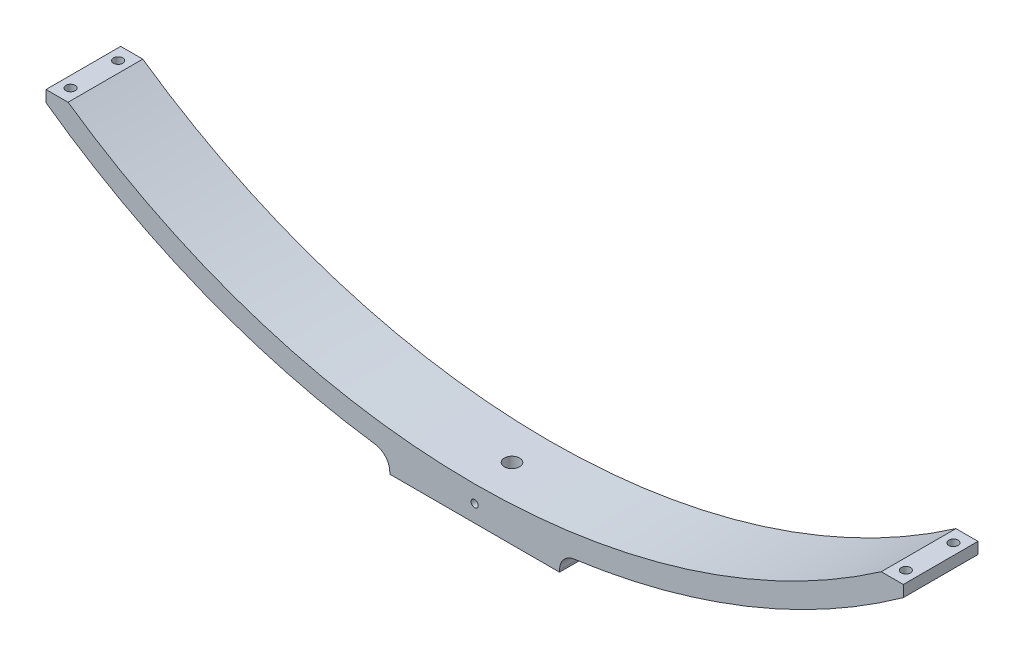
from build123d import *

# Parameters (mm, degrees)
BOSS_EXTRU_1_DEPTH       = 44
ESQUISSE2_R              = 4.5
ENL_V_MAT_EXTRU_1_DEPTH  = 96
ESQUISSE6_R              = 2.75
ENL_V_MAT_EXTRU_2_DEPTH  = 96.0000001
ESQUISSE7_R              = 4.75
ENL_V_MAT_EXTRU_3_DEPTH  = 24
ESQUISSE8_R              = 2.75
ENL_V_MAT_EXTRU_4_DEPTH  = 96.0000001
ESQUISSE9_R              = 4.75
ENL_V_MAT_EXTRU_5_DEPTH  = 24
ESQUISSE10_R             = 2.75
ENL_V_MAT_EXTRU_6_DEPTH  = 96.0000001
ESQUISSE11_R             = 4.75
ENL_V_MAT_EXTRU_8_DEPTH  = 24
ESQUISSE13_R             = 4.75
ENL_V_MAT_EXTRU_11_DEPTH = 24
TROU_TARAUD_M51_D        = 4.2
CONG_1_R                 = 10


with BuildPart() as part:
    # Esquisse1 → Boss.-Extru.1 (new body)
    with BuildSketch(Plane.XY):
        with BuildLine():
            Line((-252.5, 75), (-252.5, 68.266055554))
            ThreePointArc((-252.5, 68.266055554), (-156.243343573, 16.179149841), (-50, -10.102813546))
            Line((-50, -10.102813546), (-50, -20))
            Line((-50, -20), (50, -20))
            Line((50, -20), (50, -10.102813546))
            ThreePointArc((50, -10.102813546), (156.243343573, 16.179149841), (252.5, 68.266055554))
            Line((252.5, 68.266055554), (252.5, 75))
            Line((252.5, 75), (239.5, 75))
            ThreePointArc((239.5, 75), (0, 0), (-239.5, 75))
            Line((-239.5, 75), (-252.5, 75))
        make_face()
    extrude(amount=BOSS_EXTRU_1_DEPTH)

    # Esquisse2 → Enlèv. mat.-Extru.1 (cut, through all)
    with BuildSketch(Plane.XZ.offset(20)):
        with Locations(Location((0, 22, 0), (0, 0, 270))):  # turned: the seam where the file's is
            Circle(ESQUISSE2_R)
    extrude(amount=-ENL_V_MAT_EXTRU_1_DEPTH, mode=Mode.SUBTRACT)

    # Esquisse6 → Enlèv. mat.-Extru.2 (cut, through all)
    with BuildSketch(Plane(origin=(0, 75, 0), x_dir=(1, 0, 0), z_dir=(0, 1, 0))):
        with Locations(Location((246, -8, 0), (0, 0, 270))):  # turned: the seam where the file's is
            Circle(ESQUISSE6_R)
    extrude(amount=-ENL_V_MAT_EXTRU_2_DEPTH, mode=Mode.SUBTRACT)

    # Esquisse7 → Enlèv. mat.-Extru.3 (cut)
    with BuildSketch(Plane(origin=(0, 45, 0), x_dir=(-1, 0, 0), z_dir=(0, 1, 0))):
        with Locations(Location((-246, 8, 0), (0, 0, 270))):  # turned: the seam where the file's is
            Circle(ESQUISSE7_R)
    extrude(amount=ENL_V_MAT_EXTRU_3_DEPTH, mode=Mode.SUBTRACT)

    # Esquisse8 → Enlèv. mat.-Extru.4 (cut, through all)
    with BuildSketch(Plane(origin=(0, 75, 0), x_dir=(1, 0, 0), z_dir=(0, 1, 0))):
        with Locations(Location((246, -36, 0), (0, 0, 270))):  # turned: the seam where the file's is
            Circle(ESQUISSE8_R)
    extrude(amount=-ENL_V_MAT_EXTRU_4_DEPTH, mode=Mode.SUBTRACT)

    # Esquisse9 → Enlèv. mat.-Extru.5 (cut)
    with BuildSketch(Plane(origin=(0, 45, 0), x_dir=(-1, 0, 0), z_dir=(0, 1, 0))):
        with Locations(Location((-246, 36, 0), (0, 0, 270))):  # turned: the seam where the file's is
            Circle(ESQUISSE9_R)
    extrude(amount=ENL_V_MAT_EXTRU_5_DEPTH, mode=Mode.SUBTRACT)

    # Esquisse10 → Enlèv. mat.-Extru.6 (cut, through all)
    with BuildSketch(Plane(origin=(0, 75, 0), x_dir=(1, 0, 0), z_dir=(0, 1, 0))):
        with Locations(Location((-246, -8, 0), (0, 0, 270))):  # turned: the seam where the file's is
            Circle(ESQUISSE10_R)
        with Locations(Location((-246, -36, 0), (0, 0, 270))):  # turned: the seam where the file's is
            Circle(ESQUISSE10_R)
    extrude(amount=-ENL_V_MAT_EXTRU_6_DEPTH, mode=Mode.SUBTRACT)

    # Esquisse11 → Enlèv. mat.-Extru.8 (cut)
    with BuildSketch(Plane(origin=(0, 45, 0), x_dir=(-1, 0, 0), z_dir=(0, 1, 0))):
        with Locations(Location((246, 8, 0), (0, 0, 270))):  # turned: the seam where the file's is
            Circle(ESQUISSE11_R)
    extrude(amount=ENL_V_MAT_EXTRU_8_DEPTH, mode=Mode.SUBTRACT)

    # Esquisse13 → Enlèv. mat.-Extru.11 (cut)
    with BuildSketch(Plane(origin=(0, 45, 0), x_dir=(-1, 0, 0), z_dir=(0, 1, 0))):
        with Locations(Location((245.795073353, 35.637141441, 0), (0, 0, 270))):  # turned: the seam where the file's is
            Circle(ESQUISSE13_R)
    extrude(amount=ENL_V_MAT_EXTRU_11_DEPTH, mode=Mode.SUBTRACT)

    # Trou taraudé M51 (through all)
    with Locations(Plane(origin=(0, 0, 0), x_dir=(-1, 0, 0), z_dir=(0, 0, -1))):
        with Locations((0, -10)):
            Hole(TROU_TARAUD_M51_D / 2)

    # Congé1
    cong_1_edges = [part.edges().sort_by_distance(p)[0] for p in [
        (-50, -10.102813546, 22),
        (50, -10.102813546, 22),
    ]]
    fillet(cong_1_edges, radius=CONG_1_R)


solid = part.part
